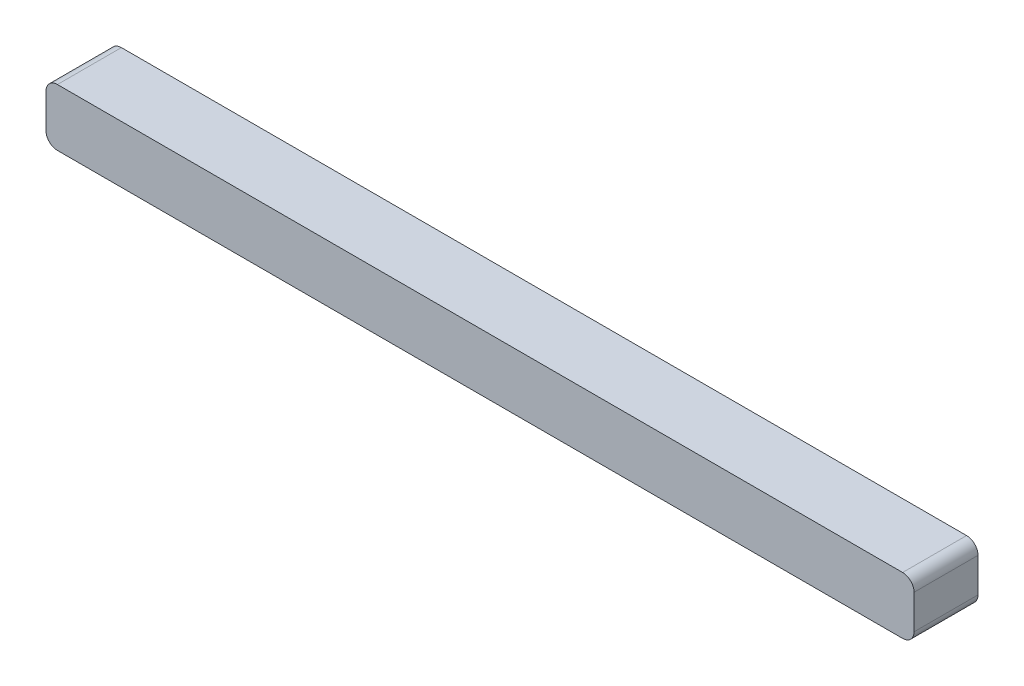
from build123d import *

# Parameters (mm, degrees)
SKETCH_1_W      = 38
SKETCH_1_H      = 2.5
EXTRUDE_1_DEPTH = 2.8
FILLET_1_R      = 0.5


with BuildPart() as part:
    # Эскиз1 → Бобышка-Вытянуть1 (new body)
    with BuildSketch(Plane.XY):
        with Locations((0.3, 0.1)):
            Rectangle(SKETCH_1_W, SKETCH_1_H)
    extrude(amount=EXTRUDE_1_DEPTH)

    # Скругление1
    fillet_1_edges = [part.edges().sort_by_distance(p)[0] for p in [
        (-18.7, 1.35, 1.4),
        (19.3, 1.35, 1.4),
        (19.3, -1.15, 1.4),
        (-18.7, -1.15, 1.4),
    ]]
    fillet(fillet_1_edges, radius=FILLET_1_R)


solid = part.part
